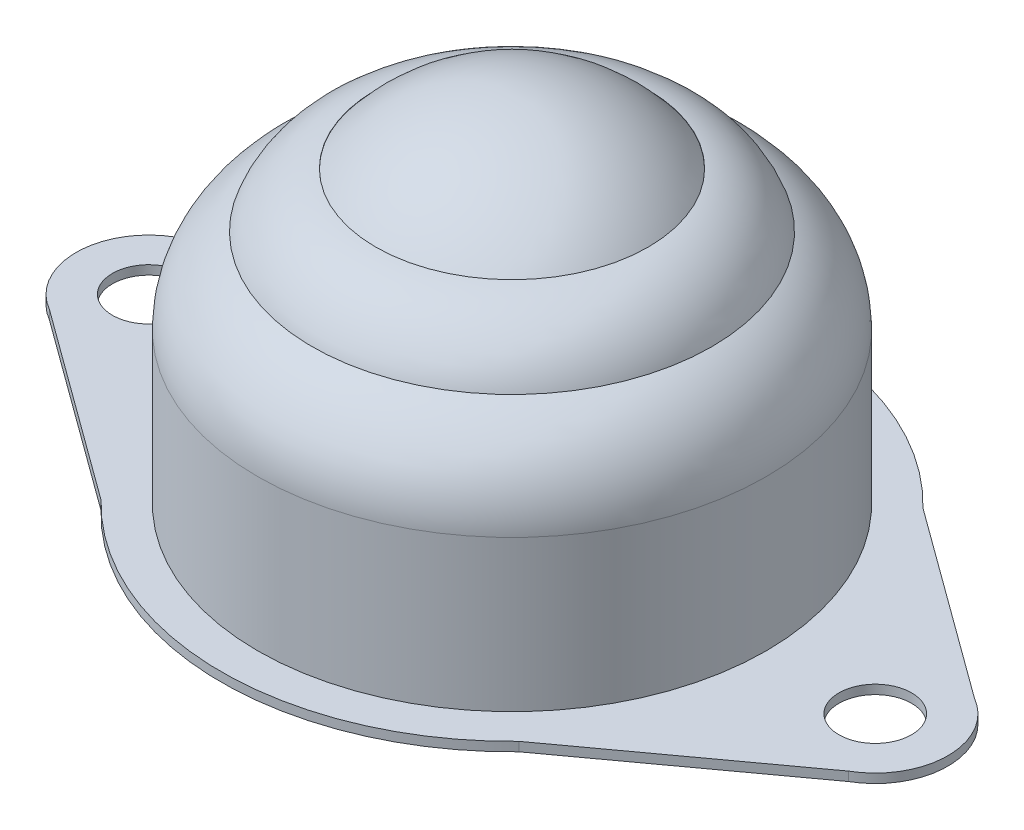
from build123d import *

# Parameters (mm, degrees)
CROQUIS2_R              = 2
SALIENTE_EXTRUIR1_DEPTH = 0.5


with BuildPart() as part:
    # Croquis1 → Revolución1 (revolve)
    with BuildSketch(Plane.XY):
        with BuildLine():
            Line((-14, 0), (-14, 8.306675448))
            ThreePointArc((-14, 8.306675448), (-13.185921926, 11.091782957), (-11, 13))
            ThreePointArc((-11, 13), (-9.655968502, 14.97362992), (-7.5, 16))
            Line((-7.5, 16), (-7.464194242, 15.803231233))
            ThreePointArc((-7.464194242, 15.803231233), (-9.558037747, 14.793881218), (-10.838145134, 12.853702577))
            ThreePointArc((-10.838145134, 12.853702577), (-12.994234558, 11.019977862), (-13.8, 8.306675448))
            Line((-13.8, 8.306675448), (-13.8, 0.2))
            Line((-13.8, 0.2), (0, 0.2))
            Line((0, 0.2), (0, 0))
            Line((0, 0), (-14, 0))
        make_face()
    revolve(axis=Axis((0, -155.434238591, 0), (0, 1, 0)))

    # Croquis2 → Saliente-Extruir1 (add)
    with BuildSketch(Plane.XZ):
        with BuildLine():
            Line((-11.5, -11.124297731), (-22, -3.464101615))
            ThreePointArc((-22, -3.464101615), (-24, 0), (-22, 3.464101615))
            Line((-22, 3.464101615), (-11.5, 11.124297731))
            ThreePointArc((-11.5, 11.124297731), (0, 16), (11.5, 11.124297731))
            Line((11.5, 11.124297731), (22, 3.464101615))
            ThreePointArc((22, 3.464101615), (24, 0), (22, -3.464101615))
            Line((22, -3.464101615), (11.5, -11.124297731))
            ThreePointArc((11.5, -11.124297731), (0, -16), (-11.5, -11.124297731))
        make_face()
        with Locations((-20, 0)):
            Circle(CROQUIS2_R, mode=Mode.SUBTRACT)
        with Locations((20, 0)):
            Circle(CROQUIS2_R, mode=Mode.SUBTRACT)
    extrude(amount=SALIENTE_EXTRUIR1_DEPTH)


with BuildPart() as body_2:
    # Croquis4 → Revolución2 (revolve)
    with BuildSketch(Plane.XY):
        with BuildLine():
            Line((0, 19.5), (0, 0))
            ThreePointArc((0, 0), (-9.75, 9.75), (0, 19.5))
        make_face()
    revolve(axis=Axis((0, 19.5, 0), (0, -1, 0)))


solid = Compound([part.part, body_2.part])
